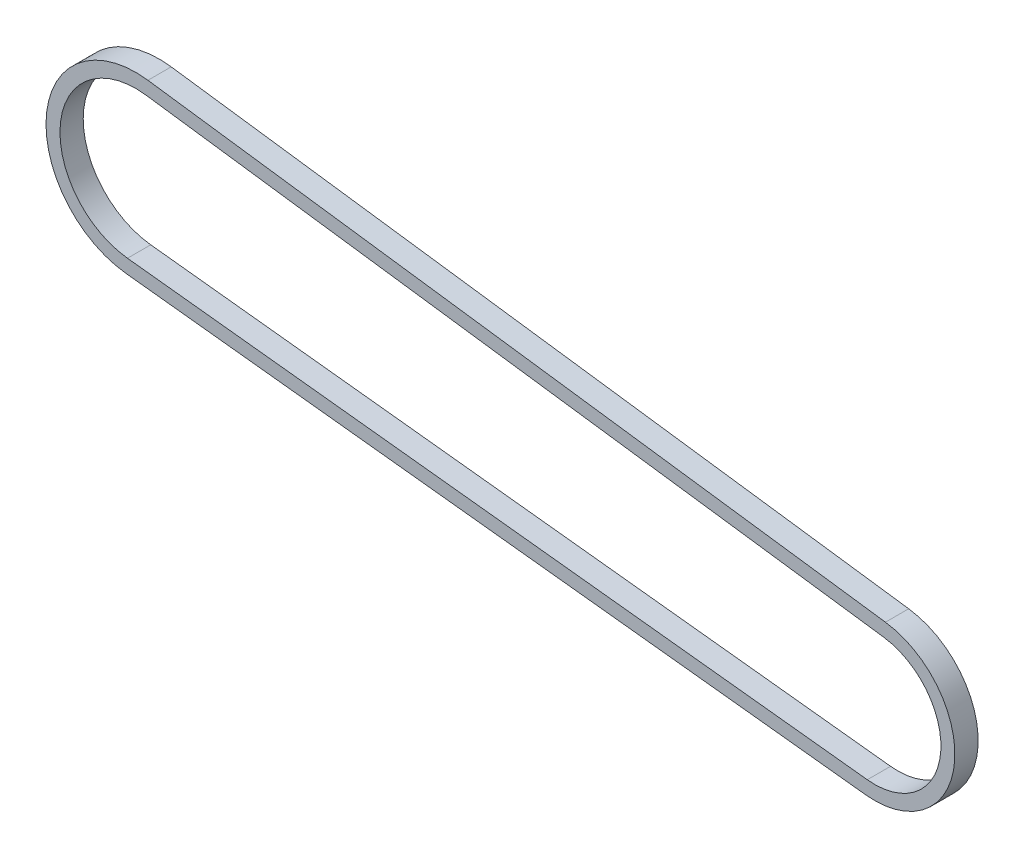
from build123d import *

# Parameters (mm, degrees)
BOSS_EXTRUDE1_DEPTH = 3.175


with BuildPart() as part:
    # Sketch1 → Boss-Extrude1 (new body)
    with BuildSketch(Plane.XY):
        with BuildLine():
            Line((-99.17960386, 24.584790198), (1.480723576, 10.859615541))
            ThreePointArc((1.480723576, 10.859615541), (10.877612048, -1.342143118), (-1.203344469, -10.893840191))
            Line((-1.203344469, -10.893840191), (-102.18090822, 0.260242363))
            ThreePointArc((-102.18090822, 0.260242363), (-112.998600241, 13.942425321), (-99.17960386, 24.584790198))
        make_face()
        with BuildLine():
            Line((-99.436971805, 22.697255631), (1.223355631, 8.972080974))
            ThreePointArc((1.223355631, 8.972080974), (8.986949467, -1.108862159), (-0.99418842, -9.000356959))
            Line((-0.99418842, -9.000356959), (-101.971752171, 2.153725595))
            ThreePointArc((-101.971752171, 2.153725595), (-111.10793766, 13.709144362), (-99.436971805, 22.697255631))
        make_face(mode=Mode.SUBTRACT)
    extrude(amount=BOSS_EXTRUDE1_DEPTH)


solid = part.part
